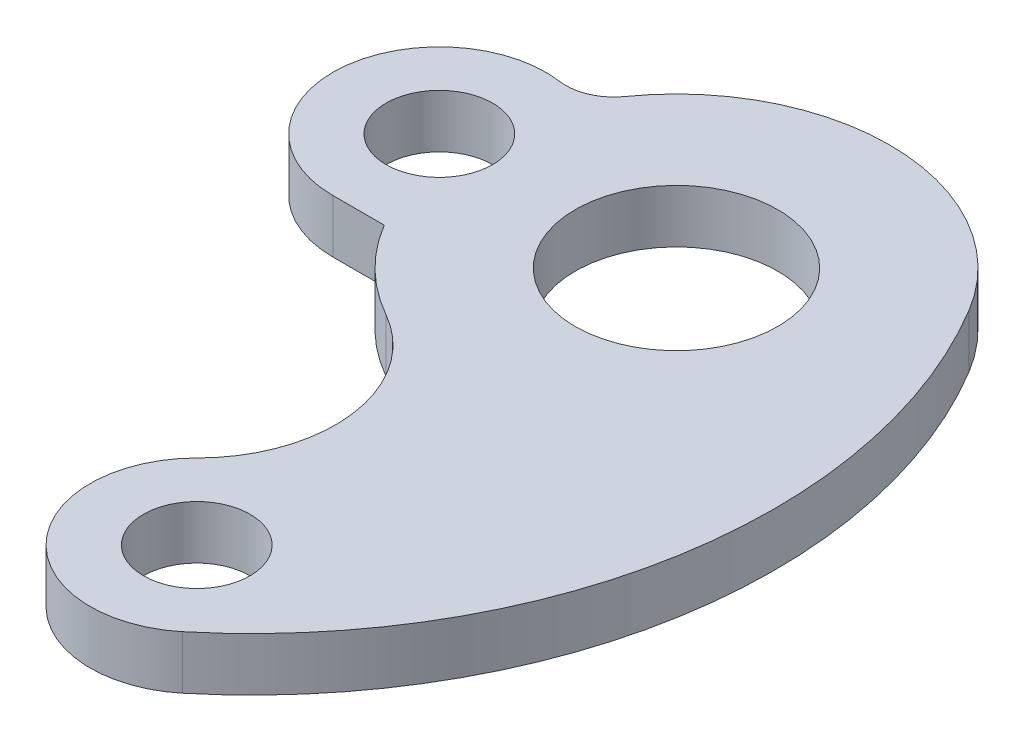
from build123d import *

# Parameters (mm, degrees)
SKETCH7_R           = 10
SKETCH7_R_2         = 19
BOSS_EXTRUDE7_DEPTH = 10


with BuildPart() as part:
    # Sketch7 → Boss-Extrude7 (new body)
    with BuildSketch(Plane(origin=(0, 0, 0), x_dir=(1, 0, 0), z_dir=(0, 1, 0))):
        with BuildLine():
            ThreePointArc((12.745045372, -105.413105413), (46.894193375, -46.39540437), (34.279777206, 20.61302682))
            ThreePointArc((34.279777206, 20.61302682), (1.47471049, 39.972806118), (-32.667709838, 23.082909998))
            ThreePointArc((-32.667709838, 23.082909998), (-36.445484769, 20.015963612), (-41.267553362, 19.363738157))
            ThreePointArc((-41.267553362, 19.363738157), (-63.99597338, 0.949285461), (-44.044461831, -20.442543154))
            Line((-44.044461831, -20.442543154), (-34.381716499, -20.442543154))
            ThreePointArc((-34.381716499, -20.442543154), (-27.977452206, -28.587797538), (-19.695904889, -34.814814815))
            ThreePointArc((-19.695904889, -34.814814815), (-6.734239862, -53.9492851), (-14.129670899, -75.845410628))
            ThreePointArc((-14.129670899, -75.845410628), (-14.800048672, -103.452083828), (12.745045372, -105.413105413))
        make_face()
        with Locations((-44.044461831, -0.442543154)):
            Circle(SKETCH7_R, mode=Mode.SUBTRACT)
        Circle(SKETCH7_R_2, mode=Mode.SUBTRACT)
        with Locations((0, -90)):
            Circle(SKETCH7_R, mode=Mode.SUBTRACT)
    extrude(amount=BOSS_EXTRUDE7_DEPTH)


solid = part.part
